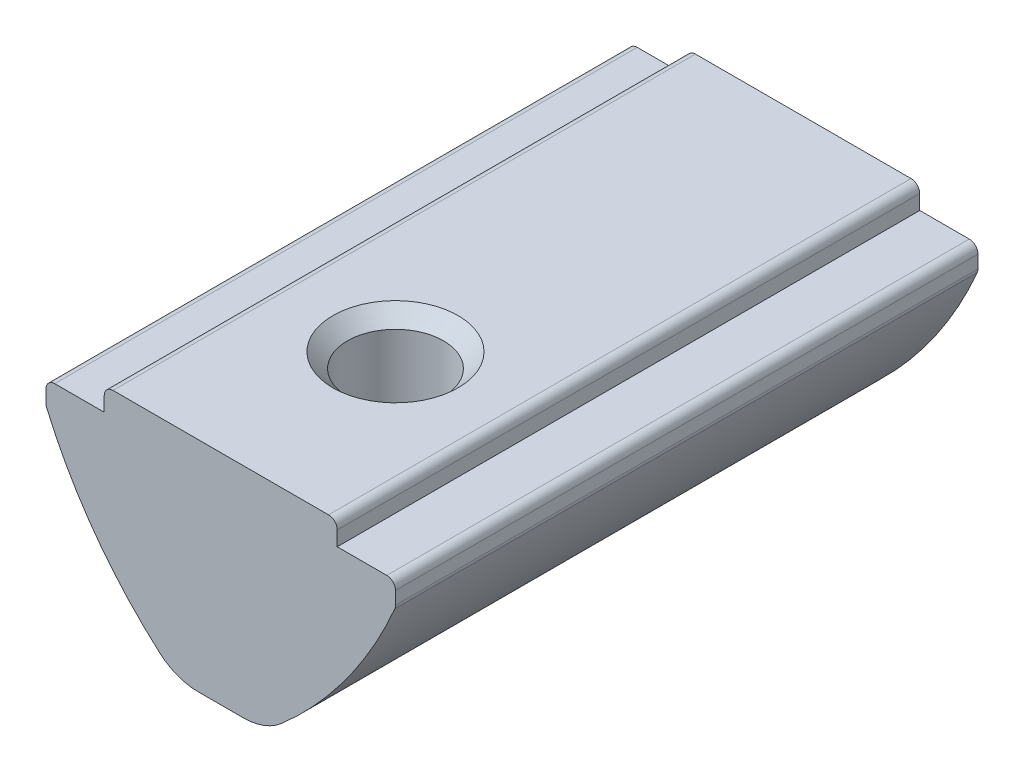
from build123d import *

# Parameters (mm, degrees)
EXTRUDE_1_DEPTH             = 10
FILLET_1_R                  = 0.3
FILLET_2_R                  = 2
HOLE_WIZARD_M41_D           = 3.3
HOLE_WIZARD_M41_CSINK_D     = 4.3
HOLE_WIZARD_M41_CSINK_ANGLE = 90


with BuildPart() as part:
    # Эскиз1 → Бобышка-Вытянуть1 (new body, symmetric)
    with BuildSketch(Plane.XY):
        with BuildLine():
            Line((-4, 0), (4, 0))
            Line((4, 0), (4, -0.8))
            Line((4, -0.8), (6, -0.8))
            Line((6, -0.8), (6, -1.6))
            ThreePointArc((6, -1.6), (4.120585945, -4.832650297), (1.5, -7.5))
            Line((1.5, -7.5), (-1.5, -7.5))
            ThreePointArc((-1.5, -7.5), (-4.120585945, -4.832650297), (-6, -1.6))
            Line((-6, -1.6), (-6, -0.8))
            Line((-6, -0.8), (-4, -0.8))
            Line((-4, -0.8), (-4, 0))
        make_face()
    extrude(amount=EXTRUDE_1_DEPTH, both=True)

    # Скругление1
    fillet_1_edges = [part.edges().sort_by_distance(p)[0] for p in [
        (6, -0.8, 0),
        (6, -1.6, 0),
        (-6, -1.6, 0),
        (-6, -0.8, 0),
        (-4, 0, 0),
        (4, 0, 0),
    ]]
    fillet(fillet_1_edges, radius=FILLET_1_R)

    # Скругление2
    fillet_2_edges = [part.edges().sort_by_distance(p)[0] for p in [
        (1.5, -7.5, 0),
        (-1.5, -7.5, 0),
    ]]
    fillet(fillet_2_edges, radius=FILLET_2_R)

    # Отверстие обработанное метчиком M41 (through all)
    with Locations(Plane(origin=(0, 0, 0), x_dir=(1, 0, 0), z_dir=(0, 1, 0))):
        with Locations((0, -4)):
            CounterSinkHole(HOLE_WIZARD_M41_D / 2, HOLE_WIZARD_M41_CSINK_D / 2, counter_sink_angle=HOLE_WIZARD_M41_CSINK_ANGLE)

    # Эскиз5 → Повернуть1 (revolve)
    with BuildSketch(Plane(origin=(0, 0, 0), x_dir=(0, 0, -1), z_dir=(1, 0, 0))):
        with BuildLine():
            Line((6, -4.3), (6, -8.3))
            ThreePointArc((6, -8.3), (4, -6.3), (6, -4.3))
        make_face()
    revolve(axis=Axis((0, -4.3, -6), (0, -1, 0)))


solid = part.part
